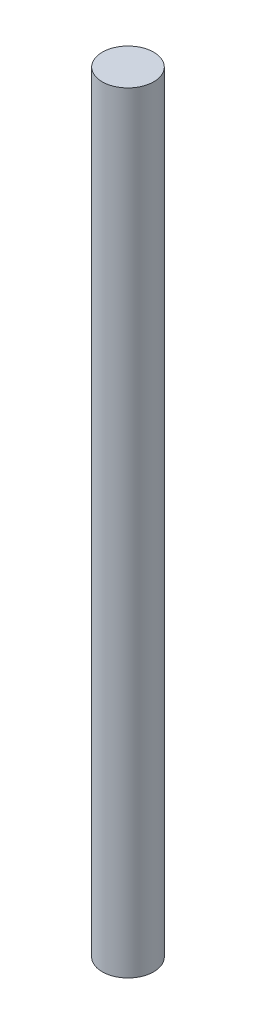
from build123d import *

# Parameters (mm, degrees)
SKETCH1_R           = 5
BOSS_EXTRUDE1_DEPTH = 150


with BuildPart() as part:
    # Sketch1 → Boss-Extrude1 (new body)
    with BuildSketch(Plane(origin=(0, 0, 0), x_dir=(1, 0, 0), z_dir=(0, 1, 0))):
        Circle(SKETCH1_R)
    extrude(amount=BOSS_EXTRUDE1_DEPTH)


solid = part.part
